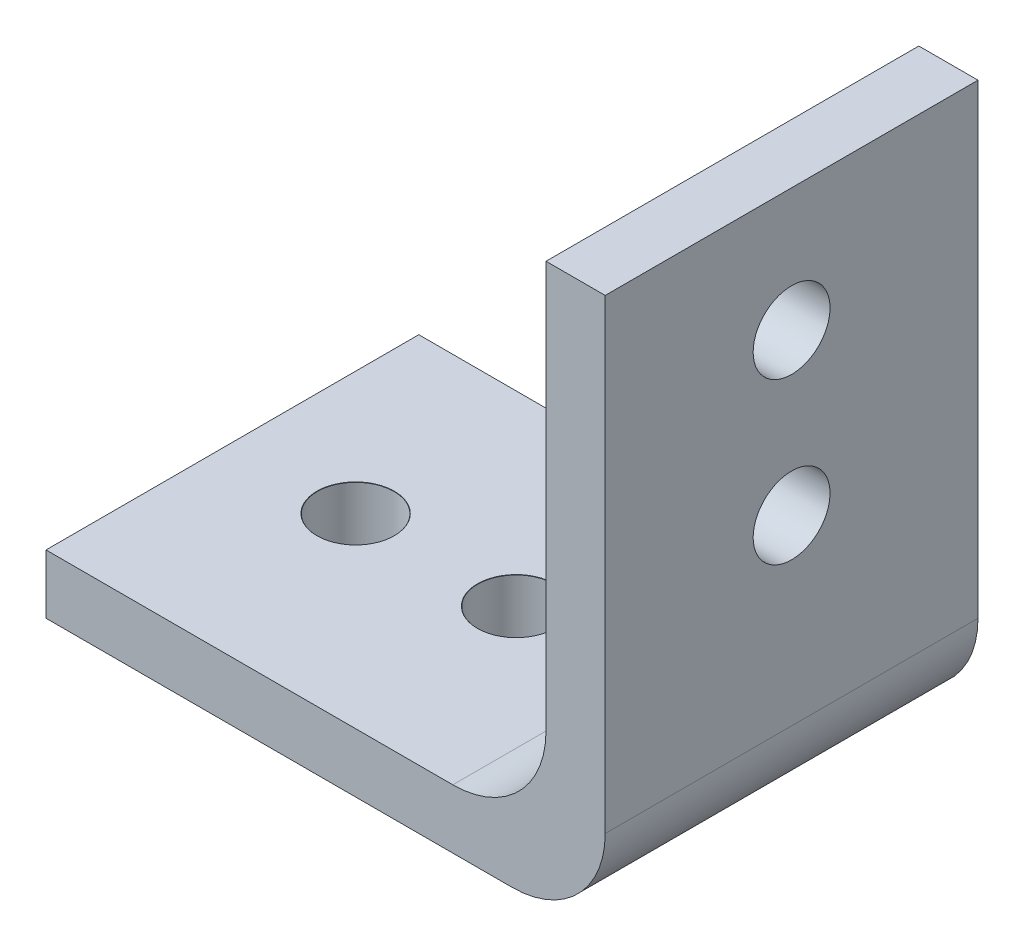
from build123d import *

# Parameters (mm, degrees)
SKETCH1_W                              = 60
SKETCH1_H                              = 40
BOSS_EXTRUDE1_DEPTH                    = 6.35
SKETCH2_W                              = 6.35
SKETCH2_H                              = 40
BOSS_EXTRUDE2_DEPTH                    = 53.65
FILLET4_R                              = 10
FILLET5_R                              = 10
TAP_DRILL_FOR_M8_HELICOIL1_D           = 8.25
TAP_DRILL_FOR_M8_HELICOIL1_CSINK_D     = 8.3
TAP_DRILL_FOR_M8_HELICOIL1_CSINK_ANGLE = 90
TAP_DRILL_FOR_M8_HELICOIL2_D           = 8.25
TAP_DRILL_FOR_M8_HELICOIL2_CSINK_D     = 8.3
TAP_DRILL_FOR_M8_HELICOIL2_CSINK_ANGLE = 90


with BuildPart() as part:
    # Sketch1 → Boss-Extrude1 (new body)
    with BuildSketch(Plane(origin=(0, 0, 0), x_dir=(1, 0, 0), z_dir=(0, 1, 0))):
        with Locations((11.612905022, -3.595670031)):
            Rectangle(SKETCH1_W, SKETCH1_H)
    extrude(amount=BOSS_EXTRUDE1_DEPTH)

    # Sketch2 → Boss-Extrude2 (add)
    with BuildSketch(Plane(origin=(0, 6.35, 0), x_dir=(1, 0, 0), z_dir=(0, 1, 0))):
        with Locations((38.437905022, -3.595670031)):
            Rectangle(SKETCH2_W, SKETCH2_H)
    extrude(amount=BOSS_EXTRUDE2_DEPTH)

    # Fillet4
    fillet4_edges = [part.edges().sort_by_distance(p)[0] for p in [
        (35.262905022, 6.35, 3.595670031),
    ]]
    fillet(fillet4_edges, radius=FILLET4_R)

    # Fillet5
    fillet5_edges = [part.edges().sort_by_distance(p)[0] for p in [
        (41.612905022, 0, 3.595670031),
    ]]
    fillet(fillet5_edges, radius=FILLET5_R)

    # Tap Drill for M8 Helicoil1 (through all)
    with Locations(Plane(origin=(0, 6.35, 0), x_dir=(1, 0, 0), z_dir=(0, 1, 0))):
        with Locations((12.052905022, -3.595670031), (-5.167094978, -3.595670031)):
            CounterSinkHole(TAP_DRILL_FOR_M8_HELICOIL1_D / 2, TAP_DRILL_FOR_M8_HELICOIL1_CSINK_D / 2, counter_sink_angle=TAP_DRILL_FOR_M8_HELICOIL1_CSINK_ANGLE)

    # Tap Drill for M8 Helicoil2 (through all)
    with Locations(Plane.ZY.offset(-35.262905022)):
        with Locations((3.595670031, 46.78), (3.595670031, 29.56)):
            CounterSinkHole(TAP_DRILL_FOR_M8_HELICOIL2_D / 2, TAP_DRILL_FOR_M8_HELICOIL2_CSINK_D / 2, counter_sink_angle=TAP_DRILL_FOR_M8_HELICOIL2_CSINK_ANGLE)


solid = part.part
